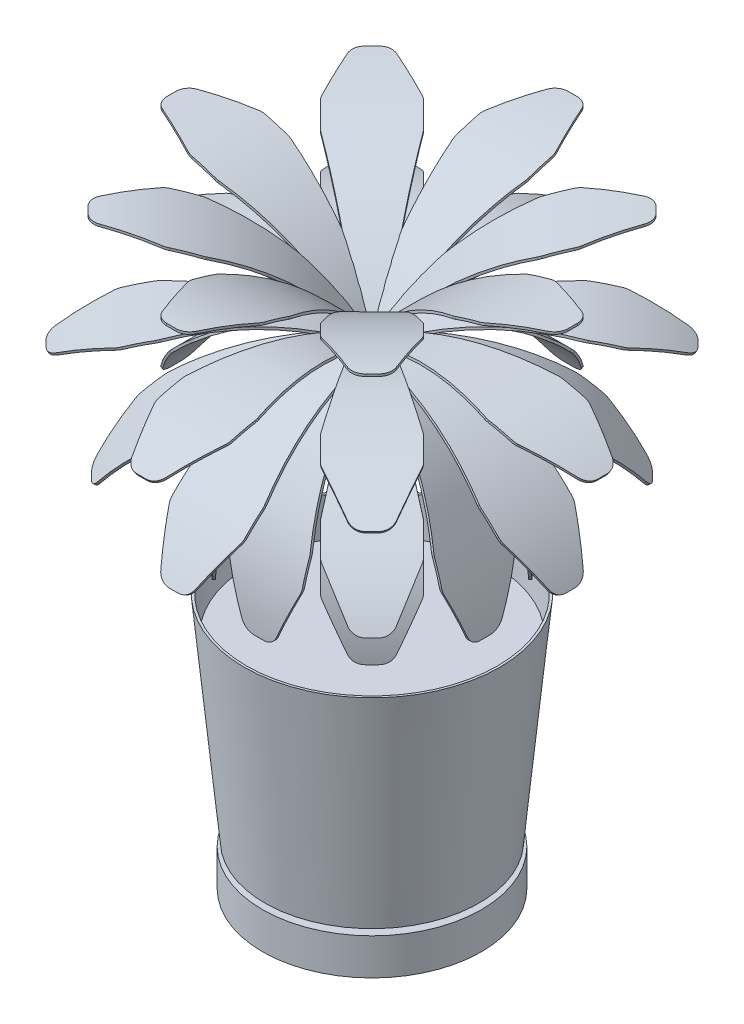
from build123d import *

# Parameters (mm, degrees)
SKETCH3_R           = 9.525
BOSS_EXTRUDE1_DEPTH = 177.8
BOSS_EXTRUDE1_TAPER = 2
BOSS_EXTRUDE2_DEPTH = 25.4
SKETCH5_OUTSIDE_W   = 263.022
SKETCH5_OUTSIDE_H   = 416.765
CUT_EXTRUDE1_DEPTH  = 89.9
FILLET6_R           = 9.525
CIRPATTERN2_COUNT   = 4
CIRPATTERN2_ANGLE   = 90
CIRPATTERN3_COUNT   = 8


with BuildPart() as part:
    # Sketch1 → Revolve1 (revolve)
    with BuildSketch(Plane.XY):
        Polygon((0, 0), (0, 152.4), (84.873325365, 152.4), (87.305240259, 177.8), (88.9, 177.8), (74.6125, 28.575), (69.85, 28.575), (69.85, 25.4), (76.2, 25.4), (76.2, 0), align=None)
    revolve(axis=Axis((0, 0, 0), (0, -1, 0)))


with BuildPart() as body_2:
    # Sketch3 → Boss-Extrude1 (new body)
    with BuildSketch(Plane(origin=(0, 152.4, 0), x_dir=(1, 0, 0), z_dir=(0, 1, 0))):
        Circle(SKETCH3_R)
    extrude(amount=BOSS_EXTRUDE1_DEPTH, taper=BOSS_EXTRUDE1_TAPER)


with BuildPart() as body_3:
    # Sketch4 → Boss-Extrude2 (new body, symmetric)
    with BuildSketch(Plane.XY):
        with BuildLine():
            Line((77.111818976, 190.5), (78.699318976, 190.5))
            ThreePointArc((78.699318976, 190.5), (57.943784129, 271.051748602), (0.846040202, 331.543269231))
            Line((0.846040202, 331.543269231), (0, 330.2))
            ThreePointArc((0, 330.2), (56.553955889, 270.284589091), (77.111818976, 190.5))
        make_face()
    extrude(amount=BOSS_EXTRUDE2_DEPTH, both=True)

    # Sketch5 outside → Cut-Extrude1 (cut, through all)
    with BuildSketch(Plane(origin=(0, 0, 0), x_dir=(0, 0, -1), z_dir=(1, 0, 0))):
        with Locations((0, 165.7715)):
            Rectangle(SKETCH5_OUTSIDE_W, SKETCH5_OUTSIDE_H)
        Polygon((-9.525, 190.5), (-25.4, 228.6), (-25.4, 247.65), (-6.35, 331.543269231), (6.35, 331.543269231), (25.4, 247.65), (25.4, 228.6), (9.525, 190.5), align=None, mode=Mode.SUBTRACT)
    extrude(amount=CUT_EXTRUDE1_DEPTH, mode=Mode.SUBTRACT)

    # Fillet6
    fillet6_edges = [body_3.edges().sort_by_distance(p)[0] for p in [
        (73.471074534, 228.6, 25.4),
        (67.750474889, 247.65, 25.4),
        (67.750474889, 247.65, -25.4),
        (73.471074534, 228.6, -25.4),
        (77.905568976, 190.5, 9.525),
        (77.905568976, 190.5, -9.525),
    ]]
    fillet(fillet6_edges, radius=FILLET6_R)


with BuildPart() as cirpattern2_1:
    # CirPattern2: pattern copy
    add(body_3.part.rotate(Axis((0, 330.2, 0), (0, 0, 1)), 1 * CIRPATTERN2_ANGLE / (CIRPATTERN2_COUNT - 1)))


with BuildPart() as cirpattern2_2:
    # CirPattern2: pattern copy
    add(body_3.part.rotate(Axis((0, 330.2, 0), (0, 0, 1)), 2 * CIRPATTERN2_ANGLE / (CIRPATTERN2_COUNT - 1)))


with BuildPart() as cirpattern2_3:
    # CirPattern2: pattern copy
    add(body_3.part.rotate(Axis((0, 330.2, 0), (0, 0, 1)), 3 * CIRPATTERN2_ANGLE / (CIRPATTERN2_COUNT - 1)))


with BuildPart() as cirpattern3_1:
    # CirPattern3: pattern copy
    add(cirpattern2_3.part.rotate(Axis((0, 0, 0), (0, 1, 0)), 1 * 360 / CIRPATTERN3_COUNT))


with BuildPart() as cirpattern3_2:
    # CirPattern3: pattern copy
    add(cirpattern2_3.part.rotate(Axis((0, 0, 0), (0, 1, 0)), 2 * 360 / CIRPATTERN3_COUNT))


with BuildPart() as cirpattern3_3:
    # CirPattern3: pattern copy
    add(cirpattern2_3.part.rotate(Axis((0, 0, 0), (0, 1, 0)), 3 * 360 / CIRPATTERN3_COUNT))


with BuildPart() as cirpattern3_4:
    # CirPattern3: pattern copy
    add(cirpattern2_3.part.rotate(Axis((0, 0, 0), (0, 1, 0)), 4 * 360 / CIRPATTERN3_COUNT))


with BuildPart() as cirpattern3_5:
    # CirPattern3: pattern copy
    add(cirpattern2_3.part.rotate(Axis((0, 0, 0), (0, 1, 0)), 5 * 360 / CIRPATTERN3_COUNT))


with BuildPart() as cirpattern3_6:
    # CirPattern3: pattern copy
    add(cirpattern2_3.part.rotate(Axis((0, 0, 0), (0, 1, 0)), 6 * 360 / CIRPATTERN3_COUNT))


with BuildPart() as cirpattern3_7:
    # CirPattern3: pattern copy
    add(cirpattern2_3.part.rotate(Axis((0, 0, 0), (0, 1, 0)), 7 * 360 / CIRPATTERN3_COUNT))


with BuildPart() as cirpattern3_8:
    # CirPattern3: pattern copy
    add(cirpattern2_2.part.rotate(Axis((0, 0, 0), (0, 1, 0)), 1 * 360 / CIRPATTERN3_COUNT))


with BuildPart() as cirpattern3_9:
    # CirPattern3: pattern copy
    add(cirpattern2_2.part.rotate(Axis((0, 0, 0), (0, 1, 0)), 2 * 360 / CIRPATTERN3_COUNT))


with BuildPart() as cirpattern3_10:
    # CirPattern3: pattern copy
    add(cirpattern2_2.part.rotate(Axis((0, 0, 0), (0, 1, 0)), 3 * 360 / CIRPATTERN3_COUNT))


with BuildPart() as cirpattern3_11:
    # CirPattern3: pattern copy
    add(cirpattern2_2.part.rotate(Axis((0, 0, 0), (0, 1, 0)), 4 * 360 / CIRPATTERN3_COUNT))


with BuildPart() as cirpattern3_12:
    # CirPattern3: pattern copy
    add(cirpattern2_2.part.rotate(Axis((0, 0, 0), (0, 1, 0)), 5 * 360 / CIRPATTERN3_COUNT))


with BuildPart() as cirpattern3_13:
    # CirPattern3: pattern copy
    add(cirpattern2_2.part.rotate(Axis((0, 0, 0), (0, 1, 0)), 6 * 360 / CIRPATTERN3_COUNT))


with BuildPart() as cirpattern3_14:
    # CirPattern3: pattern copy
    add(cirpattern2_2.part.rotate(Axis((0, 0, 0), (0, 1, 0)), 7 * 360 / CIRPATTERN3_COUNT))


with BuildPart() as cirpattern3_15:
    # CirPattern3: pattern copy
    add(cirpattern2_1.part.rotate(Axis((0, 0, 0), (0, 1, 0)), 1 * 360 / CIRPATTERN3_COUNT))


with BuildPart() as cirpattern3_16:
    # CirPattern3: pattern copy
    add(cirpattern2_1.part.rotate(Axis((0, 0, 0), (0, 1, 0)), 2 * 360 / CIRPATTERN3_COUNT))


with BuildPart() as cirpattern3_17:
    # CirPattern3: pattern copy
    add(cirpattern2_1.part.rotate(Axis((0, 0, 0), (0, 1, 0)), 3 * 360 / CIRPATTERN3_COUNT))


with BuildPart() as cirpattern3_18:
    # CirPattern3: pattern copy
    add(cirpattern2_1.part.rotate(Axis((0, 0, 0), (0, 1, 0)), 4 * 360 / CIRPATTERN3_COUNT))


with BuildPart() as cirpattern3_19:
    # CirPattern3: pattern copy
    add(cirpattern2_1.part.rotate(Axis((0, 0, 0), (0, 1, 0)), 5 * 360 / CIRPATTERN3_COUNT))


with BuildPart() as cirpattern3_20:
    # CirPattern3: pattern copy
    add(cirpattern2_1.part.rotate(Axis((0, 0, 0), (0, 1, 0)), 6 * 360 / CIRPATTERN3_COUNT))


with BuildPart() as cirpattern3_21:
    # CirPattern3: pattern copy
    add(cirpattern2_1.part.rotate(Axis((0, 0, 0), (0, 1, 0)), 7 * 360 / CIRPATTERN3_COUNT))


with BuildPart() as cirpattern3_22:
    # CirPattern3: pattern copy
    add(body_3.part.rotate(Axis((0, 0, 0), (0, 1, 0)), 1 * 360 / CIRPATTERN3_COUNT))


with BuildPart() as cirpattern3_23:
    # CirPattern3: pattern copy
    add(body_3.part.rotate(Axis((0, 0, 0), (0, 1, 0)), 2 * 360 / CIRPATTERN3_COUNT))


with BuildPart() as cirpattern3_24:
    # CirPattern3: pattern copy
    add(body_3.part.rotate(Axis((0, 0, 0), (0, 1, 0)), 3 * 360 / CIRPATTERN3_COUNT))


with BuildPart() as cirpattern3_25:
    # CirPattern3: pattern copy
    add(body_3.part.rotate(Axis((0, 0, 0), (0, 1, 0)), 4 * 360 / CIRPATTERN3_COUNT))


with BuildPart() as cirpattern3_26:
    # CirPattern3: pattern copy
    add(body_3.part.rotate(Axis((0, 0, 0), (0, 1, 0)), 5 * 360 / CIRPATTERN3_COUNT))


with BuildPart() as cirpattern3_27:
    # CirPattern3: pattern copy
    add(body_3.part.rotate(Axis((0, 0, 0), (0, 1, 0)), 6 * 360 / CIRPATTERN3_COUNT))


with BuildPart() as cirpattern3_28:
    # CirPattern3: pattern copy
    add(body_3.part.rotate(Axis((0, 0, 0), (0, 1, 0)), 7 * 360 / CIRPATTERN3_COUNT))


solid = Compound([part.part, body_2.part, body_3.part, cirpattern2_1.part, cirpattern2_2.part, cirpattern2_3.part, cirpattern3_1.part, cirpattern3_2.part, cirpattern3_3.part, cirpattern3_4.part, cirpattern3_5.part, cirpattern3_6.part, cirpattern3_7.part, cirpattern3_8.part, cirpattern3_9.part, cirpattern3_10.part, cirpattern3_11.part, cirpattern3_12.part, cirpattern3_13.part, cirpattern3_14.part, cirpattern3_15.part, cirpattern3_16.part, cirpattern3_17.part, cirpattern3_18.part, cirpattern3_19.part, cirpattern3_20.part, cirpattern3_21.part, cirpattern3_22.part, cirpattern3_23.part, cirpattern3_24.part, cirpattern3_25.part, cirpattern3_26.part, cirpattern3_27.part, cirpattern3_28.part])
